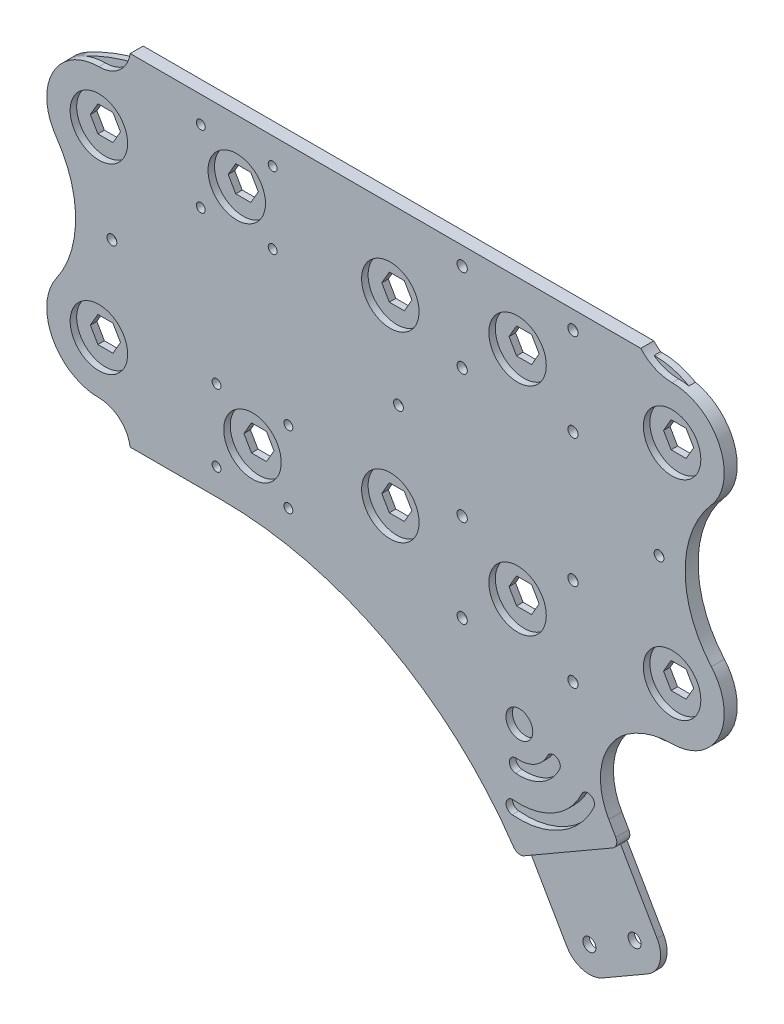
from build123d import *

# Parameters (mm, degrees)
SKETCH1_R               = 2.159
SKETCH1_R_2             = 2.5
SKETCH1_R_3             = 3.175
BOSS_EXTRUDE3_DEPTH     = 3.175
SKETCH4_R               = 14
SKETCH4_R_2             = 2.38125
SKETCH4_R_3             = 2.159
SKETCH4_R_4             = 2.5
SKETCH4_R_5             = 6.54812
BOSS_EXTRUDE4_DEPTH     = 6.35
FILLET1_R               = 2.54
CUT_EXTRUDE2_DEPTH      = 1
CUT_EXTRUDE2_DEPTH_BACK = 7.35
FILLET2_R               = 3.81


with BuildPart() as part:
    # Sketch1 → Boss-Extrude3 (new body)
    with BuildSketch(Plane.XY):
        with BuildLine():
            Line((113.584291992, 80.1116), (113.584291992, 54.7116))
            Line((113.584291992, 54.7116), (88.184291992, 54.7116))
            Line((88.184291992, 54.7116), (88.184291992, 80.1116))
            Line((88.184291992, 80.1116), (39.822691992, 80.1116))
            ThreePointArc((39.822691992, 80.1116), (12.922826287, 76.701489547), (-12.275183404, 66.686903391))
            ThreePointArc((-12.275183404, 66.686903391), (-25.397490808, 44.807016355), (-12.895384615, 22.566923077))
            ThreePointArc((-12.895384615, 22.566923077), (0, 0), (-12.895384615, -22.566923077))
            ThreePointArc((-12.895384615, -22.566923077), (-25.397490808, -44.807016355), (-12.275183404, -66.686903391))
            ThreePointArc((-12.275183404, -66.686903391), (7.438885646, -75.132543085), (28.434721687, -79.50841069))
            Line((28.434721687, -79.50841069), (28.434721687, -54.7116))
            Line((28.434721687, -54.7116), (53.834721687, -54.7116))
            Line((53.834721687, -54.7116), (53.834721687, -80.1116))
            Line((53.834721687, -80.1116), (131.769044239, -80.1116))
            ThreePointArc((131.769044239, -80.1116), (157.169044239, -86.917509488), (175.763134751, -105.5116))
            Line((175.763134751, -105.5116), (224.861657379, -190.552735768))
            ThreePointArc((224.861657379, -190.552735768), (232.573178135, -196.469993762), (242.210180007, -195.201258396))
            Line((242.210180007, -195.201258396), (264.207225263, -182.501258396))
            ThreePointArc((264.207225263, -182.501258396), (270.124483257, -174.789737641), (268.855747892, -165.152735768))
            Line((268.855747892, -165.152735768), (230.755747892, -99.1616))
            ThreePointArc((230.755747892, -99.1616), (230.755747892, -86.4616), (241.75427052, -80.1116))
            Line((241.75427052, -80.1116), (268.191665038, -80.1116))
            ThreePointArc((268.191665038, -80.1116), (298.862941972, -56.567407166), (284.04568608, -20.853191889))
            ThreePointArc((284.04568608, -20.853191889), (271.99548317, 0), (284.04568608, 20.853191889))
            ThreePointArc((284.04568608, 20.853191889), (298.862941972, 56.567407166), (268.191665038, 80.1116))
            Line((268.191665038, 80.1116), (113.584291992, 80.1116))
        make_face()
        with Locations((49.675972812, 35.25328082)):
            Circle(SKETCH1_R, mode=Mode.SUBTRACT)
        with Locations((49.675972812, 70.25831918)):
            Circle(SKETCH1_R, mode=Mode.SUBTRACT)
        with Locations((84.681011172, 35.25328082)):
            Circle(SKETCH1_R, mode=Mode.SUBTRACT)
        with Locations((84.681011172, 70.25831918)):
            Circle(SKETCH1_R, mode=Mode.SUBTRACT)
        with Locations((231.027831589, 74.2058)):
            Circle(SKETCH1_R_2, mode=Mode.SUBTRACT)
        with Locations((231.027831589, 31.3058)):
            Circle(SKETCH1_R_2, mode=Mode.SUBTRACT)
        with Locations((216.810180007, -151.207167884)):
            Circle(SKETCH1_R_3, mode=Mode.SUBTRACT)
        with Locations((235.860180007, -184.202735768)):
            Circle(SKETCH1_R_3, mode=Mode.SUBTRACT)
        with Locations((257.857225263, -171.502735768)):
            Circle(SKETCH1_R_3, mode=Mode.SUBTRACT)
        with Locations((238.807225263, -138.507167884)):
            Circle(SKETCH1_R_3, mode=Mode.SUBTRACT)
        with Locations((197.760180007, -118.2116)):
            Circle(SKETCH1_R_3, mode=Mode.SUBTRACT)
        with Locations((177.027831589, -74.2058)):
            Circle(SKETCH1_R_2, mode=Mode.SUBTRACT)
        with Locations((219.757225263, -105.5116)):
            Circle(SKETCH1_R_3, mode=Mode.SUBTRACT)
        with Locations((231.027831589, -74.2058)):
            Circle(SKETCH1_R_2, mode=Mode.SUBTRACT)
        with Locations((177.027831589, -31.3058)):
            Circle(SKETCH1_R_2, mode=Mode.SUBTRACT)
        with Locations((231.027831589, -31.3058)):
            Circle(SKETCH1_R_2, mode=Mode.SUBTRACT)
        with Locations((177.027831589, 31.3058)):
            Circle(SKETCH1_R_2, mode=Mode.SUBTRACT)
        with Locations((177.027831589, 74.2058)):
            Circle(SKETCH1_R_2, mode=Mode.SUBTRACT)
        with Locations((92.343040867, -35.25328082)):
            Circle(SKETCH1_R, mode=Mode.SUBTRACT)
        with Locations((57.338002507, -35.25328082)):
            Circle(SKETCH1_R, mode=Mode.SUBTRACT)
        with Locations((92.343040867, -70.25831918)):
            Circle(SKETCH1_R, mode=Mode.SUBTRACT)
        with Locations((57.338002507, -70.25831918)):
            Circle(SKETCH1_R, mode=Mode.SUBTRACT)
        Polygon((74.510840411, 52.7558), (70.844666202, 46.4058), (63.512317783, 46.4058), (59.846143574, 52.7558), (63.512317783, 59.1058), (70.844666202, 59.1058), align=None, mode=Mode.SUBTRACT)
        Polygon((207.694005798, 59.1058), (211.360180007, 52.7558), (207.694005798, 46.4058), (200.361657379, 46.4058), (196.69548317, 52.7558), (200.361657379, 59.1058), align=None, mode=Mode.SUBTRACT)
        Polygon((282.994005798, 57.15), (286.660180007, 50.8), (282.994005798, 44.45), (275.661657379, 44.45), (271.99548317, 50.8), (275.661657379, 57.15), align=None, mode=Mode.SUBTRACT)
        Polygon((286.660180007, -50.8), (282.994005798, -57.15), (275.661657379, -57.15), (271.99548317, -50.8), (275.661657379, -44.45), (282.994005798, -44.45), align=None, mode=Mode.SUBTRACT)
        Polygon((207.694005798, -46.4058), (211.360180007, -52.7558), (207.694005798, -59.1058), (200.361657379, -59.1058), (196.69548317, -52.7558), (200.361657379, -46.4058), align=None, mode=Mode.SUBTRACT)
        Polygon((78.506695896, -46.4058), (82.172870106, -52.7558), (78.506695896, -59.1058), (71.174347477, -59.1058), (67.508173268, -52.7558), (71.174347477, -46.4058), align=None, mode=Mode.SUBTRACT)
        Polygon((3.666174209, 50.8), (7.332348419, 44.45), (3.666174209, 38.1), (-3.666174209, 38.1), (-7.332348419, 44.45), (-3.666174209, 50.8), align=None, mode=Mode.SUBTRACT)
        Polygon((7.332348419, -44.45), (3.666174209, -50.8), (-3.666174209, -50.8), (-7.332348419, -44.45), (-3.666174209, -38.1), (3.666174209, -38.1), align=None, mode=Mode.SUBTRACT)
        Polygon((145.685187889, 50.8), (149.351362098, 44.45), (145.685187889, 38.1), (138.35283947, 38.1), (134.68666526, 44.45), (138.35283947, 50.8), align=None, mode=Mode.SUBTRACT)
        Polygon((149.351362098, -44.45), (145.685187889, -50.8), (138.35283947, -50.8), (134.68666526, -44.45), (138.35283947, -38.1), (145.685187889, -38.1), align=None, mode=Mode.SUBTRACT)
    extrude(amount=BOSS_EXTRUDE3_DEPTH)


with BuildPart() as body_2:
    # Sketch4 → Boss-Extrude4 (new body)
    with BuildSketch(Plane.XY):
        with BuildLine():
            Line((15.24, 83.0558), (264.087831589, 83.0558))
            ThreePointArc((264.087831589, 83.0558), (270.972300582, 77.992862142), (279.327831589, 76.2))
            ThreePointArc((279.327831589, 76.2), (302.451140116, 61.310594785), (298.46481789, 34.098630137))
            ThreePointArc((298.46481789, 34.098630137), (285.677831589, 0), (298.46481789, -34.098630137))
            ThreePointArc((298.46481789, -34.098630137), (302.451140116, -61.310594785), (279.327831589, -76.2))
            ThreePointArc((279.327831589, -76.2), (267.899665069, -77.954339874), (257.523933626, -83.0558))
            ThreePointArc((257.523933626, -83.0558), (245.131598289, -101.554723393), (248.51009846, -123.56303724))
            Line((248.51009846, -123.56303724), (264.565147031, -151.371197082))
            Line((264.565147031, -151.371197082), (215.071795204, -179.946197082))
            Line((215.071795204, -179.946197082), (208.721795204, -168.947674454))
            ThreePointArc((208.721795204, -168.947674454), (145.844579146, -106.070458396), (59.952704692, -83.0558))
            Line((59.952704692, -83.0558), (15.24, -83.0558))
            ThreePointArc((15.24, -83.0558), (10.082791697, -73.610743867), (0, -69.85))
            ThreePointArc((0, -69.85), (-22.542714402, -56.154103015), (-20.774980442, -29.83630137))
            ThreePointArc((-20.774980442, -29.83630137), (-11.332232176, 0), (-20.774980442, 29.83630137))
            ThreePointArc((-20.774980442, 29.83630137), (-22.542714402, 56.154103015), (0, 69.85))
            ThreePointArc((0, 69.85), (10.082791697, 73.610743867), (15.24, 83.0558))
        make_face()
        with Locations((0, 44.45)):
            Circle(SKETCH4_R, mode=Mode.SUBTRACT)
        with Locations((142.019013679, 44.45)):
            Circle(SKETCH4_R, mode=Mode.SUBTRACT)
        with Locations((279.327831589, 50.8)):
            Circle(SKETCH4_R, mode=Mode.SUBTRACT)
        with Locations((279.327831589, -50.8)):
            Circle(SKETCH4_R, mode=Mode.SUBTRACT)
        with Locations((142.019013679, -44.45)):
            Circle(SKETCH4_R, mode=Mode.SUBTRACT)
        with Locations((0, -44.45)):
            Circle(SKETCH4_R, mode=Mode.SUBTRACT)
        with Locations((67.178491992, 52.7558)):
            Circle(SKETCH4_R, mode=Mode.SUBTRACT)
        with Locations((204.027831589, 52.7558)):
            Circle(SKETCH4_R, mode=Mode.SUBTRACT)
        with Locations((204.027831589, -52.7558)):
            Circle(SKETCH4_R, mode=Mode.SUBTRACT)
        with Locations((74.840521687, -52.7558)):
            Circle(SKETCH4_R, mode=Mode.SUBTRACT)
        with Locations((6.35, 0)):
            Circle(SKETCH4_R_2, mode=Mode.SUBTRACT)
        with Locations((272.977831589, 0)):
            Circle(SKETCH4_R_2, mode=Mode.SUBTRACT)
        with Locations((145.977831589, 0)):
            Circle(SKETCH4_R_2, mode=Mode.SUBTRACT)
        with Locations((92.343040867, -70.25831918)):
            Circle(SKETCH4_R_3, mode=Mode.SUBTRACT)
        with Locations((57.338002507, -70.25831918)):
            Circle(SKETCH4_R_3, mode=Mode.SUBTRACT)
        with Locations((57.338002507, -35.25328082)):
            Circle(SKETCH4_R_3, mode=Mode.SUBTRACT)
        with Locations((92.343040867, -35.25328082)):
            Circle(SKETCH4_R_3, mode=Mode.SUBTRACT)
        with Locations((177.027831589, -74.2058)):
            Circle(SKETCH4_R_4, mode=Mode.SUBTRACT)
        with Locations((231.027831589, -74.2058)):
            Circle(SKETCH4_R_4, mode=Mode.SUBTRACT)
        with Locations((231.027831589, -31.3058)):
            Circle(SKETCH4_R_4, mode=Mode.SUBTRACT)
        with Locations((177.027831589, -31.3058)):
            Circle(SKETCH4_R_4, mode=Mode.SUBTRACT)
        with Locations((231.027831589, 31.3058)):
            Circle(SKETCH4_R_4, mode=Mode.SUBTRACT)
        with Locations((231.027831589, 74.2058)):
            Circle(SKETCH4_R_4, mode=Mode.SUBTRACT)
        with Locations((177.027831589, 31.3058)):
            Circle(SKETCH4_R_4, mode=Mode.SUBTRACT)
        with Locations((177.027831589, 74.2058)):
            Circle(SKETCH4_R_4, mode=Mode.SUBTRACT)
        with Locations((49.675972812, 35.25328082)):
            Circle(SKETCH4_R_3, mode=Mode.SUBTRACT)
        with Locations((84.681011172, 35.25328082)):
            Circle(SKETCH4_R_3, mode=Mode.SUBTRACT)
        with Locations((84.681011172, 70.25831918)):
            Circle(SKETCH4_R_3, mode=Mode.SUBTRACT)
        with Locations((49.675972812, 70.25831918)):
            Circle(SKETCH4_R_3, mode=Mode.SUBTRACT)
        with Locations((204.893471118, -105.166822628)):
            Circle(SKETCH4_R_5, mode=Mode.SUBTRACT)
        with BuildLine():
            ThreePointArc((201.399057483, -145.108153234), (224.940421118, -139.889158565), (241.2308849, -122.111236952))
            ThreePointArc((241.2308849, -122.111236952), (239.652170659, -117.773755222), (235.314688928, -119.352469463))
            ThreePointArc((235.314688928, -119.352469463), (221.676521118, -134.235917934), (201.967992741, -138.605193484))
            ThreePointArc((201.967992741, -138.605193484), (198.432045237, -141.57220573), (201.399057483, -145.108153234))
        make_face(mode=Mode.SUBTRACT)
        with BuildLine():
            ThreePointArc((203.004030486, -126.763227869), (215.732921118, -123.941300754), (224.541227002, -114.328721663))
            ThreePointArc((224.541227002, -114.328721663), (222.96251276, -109.991239932), (218.62503103, -111.569954174))
            ThreePointArc((218.62503103, -111.569954174), (212.469021118, -118.288060123), (203.572965744, -120.260268118))
            ThreePointArc((203.572965744, -120.260268118), (200.03701824, -123.227280365), (203.004030486, -126.763227869))
        make_face(mode=Mode.SUBTRACT)
    extrude(amount=BOSS_EXTRUDE4_DEPTH)

    # Fillet1
    fillet1_edges = [body_2.edges().sort_by_distance(p)[0] for p in [
        (264.565147031, -151.371197082, 3.175),
        (215.071795204, -179.946197082, 3.175),
    ]]
    fillet(fillet1_edges, radius=FILLET1_R)

    # Sketch5 → Cut-Extrude2 (cut, two sides)
    with BuildSketch(Plane.XY.offset(6.35)) as cut_extrude2_sk:
        with BuildLine():
            Line((263.295147031, -149.171492557), (253.770147031, -132.673708615))
            Line((253.770147031, -132.673708615), (204.077446621, -161.363802573))
            ThreePointArc((204.077446621, -161.363802573), (206.448704804, -165.125679633), (208.721795204, -168.947674454))
            Line((208.721795204, -168.947674454), (213.801795204, -177.746492557))
            ThreePointArc((213.801795204, -177.746492557), (215.344099355, -178.929944156), (217.27149973, -178.676197082))
            Line((217.27149973, -178.676197082), (262.365442505, -152.641197082))
            ThreePointArc((262.365442505, -152.641197082), (263.548894104, -151.098892931), (263.295147031, -149.171492557))
        make_face()
    extrude(amount=CUT_EXTRUDE2_DEPTH, mode=Mode.SUBTRACT)
    extrude(cut_extrude2_sk.sketch, amount=-CUT_EXTRUDE2_DEPTH_BACK, mode=Mode.SUBTRACT)

    # Fillet2
    fillet2_edges = [body_2.edges().sort_by_distance(p)[0] for p in [
        (204.077446621, -161.363802573, 3.175),
        (253.770147031, -132.673708615, 3.175),
    ]]
    fillet(fillet2_edges, radius=FILLET2_R)


solid = Compound([part.part, body_2.part])
